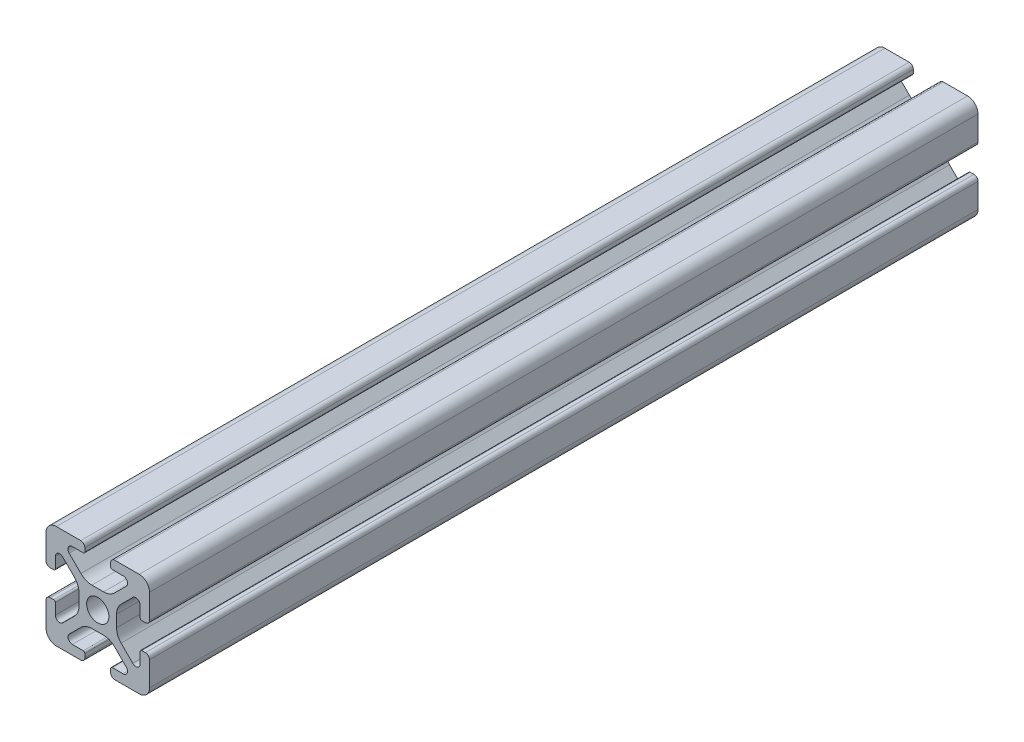
from build123d import *

# Parameters (mm, degrees)
SKETCH1_R           = 2.1463
BOSS_EXTRUDE1_DEPTH = 80


with BuildPart() as part:
    # Sketch1 → Boss-Extrude1 (new body, symmetric)
    with BuildSketch(Plane.XY):
        with BuildLine():
            Line((-9.9949, 7.9883), (-9.9949, 3.2893))
            ThreePointArc((-9.9949, 3.2893), (-9.76427588, 2.73252412), (-9.2075, 2.5019))
            Line((-9.2075, 2.5019), (-8.4963, 2.5019))
            ThreePointArc((-8.4963, 2.5019), (-8.280773853, 2.591173853), (-8.1915, 2.8067))
            Line((-8.1915, 2.8067), (-8.1915, 4.9149))
            ThreePointArc((-8.1915, 4.9149), (-7.674065253, 5.689295824), (-6.760603096, 5.507596904))
            Line((-6.760603096, 5.507596904), (-4.505765747, 3.252759555))
            ThreePointArc((-4.505765747, 3.252759555), (-3.856054457, 2.280397894), (-3.627906192, 1.133419111))
            Line((-3.627906192, 1.133419111), (-3.627906192, -1.133419111))
            ThreePointArc((-3.627906192, -1.133419111), (-3.856054457, -2.280397894), (-4.505765747, -3.252759555))
            Line((-4.505765747, -3.252759555), (-6.760603096, -5.507596904))
            ThreePointArc((-6.760603096, -5.507596904), (-7.674065253, -5.689295824), (-8.1915, -4.9149))
            Line((-8.1915, -4.9149), (-8.1915, -2.8067))
            ThreePointArc((-8.1915, -2.8067), (-8.280773853, -2.591173853), (-8.4963, -2.5019))
            Line((-8.4963, -2.5019), (-9.2075, -2.5019))
            ThreePointArc((-9.2075, -2.5019), (-9.76427588, -2.73252412), (-9.9949, -3.2893))
            Line((-9.9949, -3.2893), (-9.9949, -7.9883))
            ThreePointArc((-9.9949, -7.9883), (-9.407180467, -9.407180467), (-7.9883, -9.9949))
            Line((-7.9883, -9.9949), (-3.2893, -9.9949))
            ThreePointArc((-3.2893, -9.9949), (-2.73252412, -9.76427588), (-2.5019, -9.2075))
            Line((-2.5019, -9.2075), (-2.5019, -8.4963))
            ThreePointArc((-2.5019, -8.4963), (-2.591173853, -8.280773853), (-2.8067, -8.1915))
            Line((-2.8067, -8.1915), (-4.9149, -8.1915))
            ThreePointArc((-4.9149, -8.1915), (-5.689295824, -7.674065253), (-5.507596904, -6.760603096))
            Line((-5.507596904, -6.760603096), (-3.252759555, -4.505765747))
            ThreePointArc((-3.252759555, -4.505765747), (-2.280397894, -3.856054457), (-1.133419111, -3.627906192))
            Line((-1.133419111, -3.627906192), (1.133419111, -3.627906192))
            ThreePointArc((1.133419111, -3.627906192), (2.280397894, -3.856054457), (3.252759555, -4.505765747))
            Line((3.252759555, -4.505765747), (5.507596904, -6.760603096))
            ThreePointArc((5.507596904, -6.760603096), (5.689295824, -7.674065253), (4.9149, -8.1915))
            Line((4.9149, -8.1915), (2.8067, -8.1915))
            ThreePointArc((2.8067, -8.1915), (2.591173853, -8.280773853), (2.5019, -8.4963))
            Line((2.5019, -8.4963), (2.5019, -9.2075))
            ThreePointArc((2.5019, -9.2075), (2.73252412, -9.76427588), (3.2893, -9.9949))
            Line((3.2893, -9.9949), (7.9883, -9.9949))
            ThreePointArc((7.9883, -9.9949), (9.407180467, -9.407180467), (9.9949, -7.9883))
            Line((9.9949, -7.9883), (9.9949, -3.2893))
            ThreePointArc((9.9949, -3.2893), (9.76427588, -2.73252412), (9.2075, -2.5019))
            Line((9.2075, -2.5019), (8.4963, -2.5019))
            ThreePointArc((8.4963, -2.5019), (8.280773853, -2.591173853), (8.1915, -2.8067))
            Line((8.1915, -2.8067), (8.1915, -4.9149))
            ThreePointArc((8.1915, -4.9149), (7.674065253, -5.689295824), (6.760603096, -5.507596904))
            Line((6.760603096, -5.507596904), (4.505765747, -3.252759555))
            ThreePointArc((4.505765747, -3.252759555), (3.856054457, -2.280397894), (3.627906192, -1.133419111))
            Line((3.627906192, -1.133419111), (3.627906192, 1.133419111))
            ThreePointArc((3.627906192, 1.133419111), (3.856054457, 2.280397894), (4.505765747, 3.252759555))
            Line((4.505765747, 3.252759555), (6.760603096, 5.507596904))
            ThreePointArc((6.760603096, 5.507596904), (7.674065253, 5.689295824), (8.1915, 4.9149))
            Line((8.1915, 4.9149), (8.1915, 2.8067))
            ThreePointArc((8.1915, 2.8067), (8.280773853, 2.591173853), (8.4963, 2.5019))
            Line((8.4963, 2.5019), (9.2075, 2.5019))
            ThreePointArc((9.2075, 2.5019), (9.76427588, 2.73252412), (9.9949, 3.2893))
            Line((9.9949, 3.2893), (9.9949, 7.9883))
            ThreePointArc((9.9949, 7.9883), (9.407180467, 9.407180467), (7.9883, 9.9949))
            Line((7.9883, 9.9949), (3.2893, 9.9949))
            ThreePointArc((3.2893, 9.9949), (2.73252412, 9.76427588), (2.5019, 9.2075))
            Line((2.5019, 9.2075), (2.5019, 8.4963))
            ThreePointArc((2.5019, 8.4963), (2.591173853, 8.280773853), (2.8067, 8.1915))
            Line((2.8067, 8.1915), (4.9149, 8.1915))
            ThreePointArc((4.9149, 8.1915), (5.689295824, 7.674065253), (5.507596904, 6.760603096))
            Line((5.507596904, 6.760603096), (3.252759555, 4.505765747))
            ThreePointArc((3.252759555, 4.505765747), (2.280397894, 3.856054457), (1.133419111, 3.627906192))
            Line((1.133419111, 3.627906192), (-1.133419111, 3.627906192))
            ThreePointArc((-1.133419111, 3.627906192), (-2.280397894, 3.856054457), (-3.252759555, 4.505765747))
            Line((-3.252759555, 4.505765747), (-5.507596904, 6.760603096))
            ThreePointArc((-5.507596904, 6.760603096), (-5.689295824, 7.674065253), (-4.9149, 8.1915))
            Line((-4.9149, 8.1915), (-2.8067, 8.1915))
            ThreePointArc((-2.8067, 8.1915), (-2.591173853, 8.280773853), (-2.5019, 8.4963))
            Line((-2.5019, 8.4963), (-2.5019, 9.2075))
            ThreePointArc((-2.5019, 9.2075), (-2.73252412, 9.76427588), (-3.2893, 9.9949))
            Line((-3.2893, 9.9949), (-7.9883, 9.9949))
            ThreePointArc((-7.9883, 9.9949), (-9.407180467, 9.407180467), (-9.9949, 7.9883))
        make_face()
        Circle(SKETCH1_R, mode=Mode.SUBTRACT)
    extrude(amount=BOSS_EXTRUDE1_DEPTH, both=True)


solid = part.part
